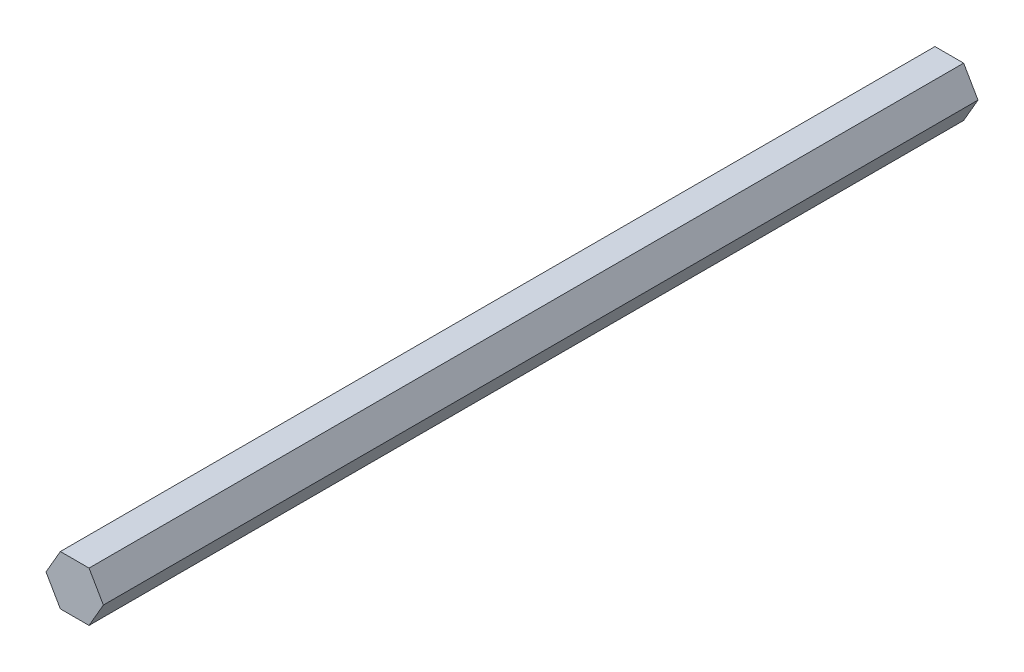
from build123d import *

# Parameters (mm, degrees)
BOSS_EXTRUDE1_DEPTH = 223.52


with BuildPart() as part:
    # Sketch1 → Boss-Extrude1 (new body)
    with BuildSketch(Plane.XY):
        Polygon((-7.332348419, 0), (-3.666174209, -6.35), (3.666174209, -6.35), (7.332348419, 0), (3.666174209, 6.35), (-3.666174209, 6.35), align=None)
    extrude(amount=BOSS_EXTRUDE1_DEPTH)


solid = part.part
